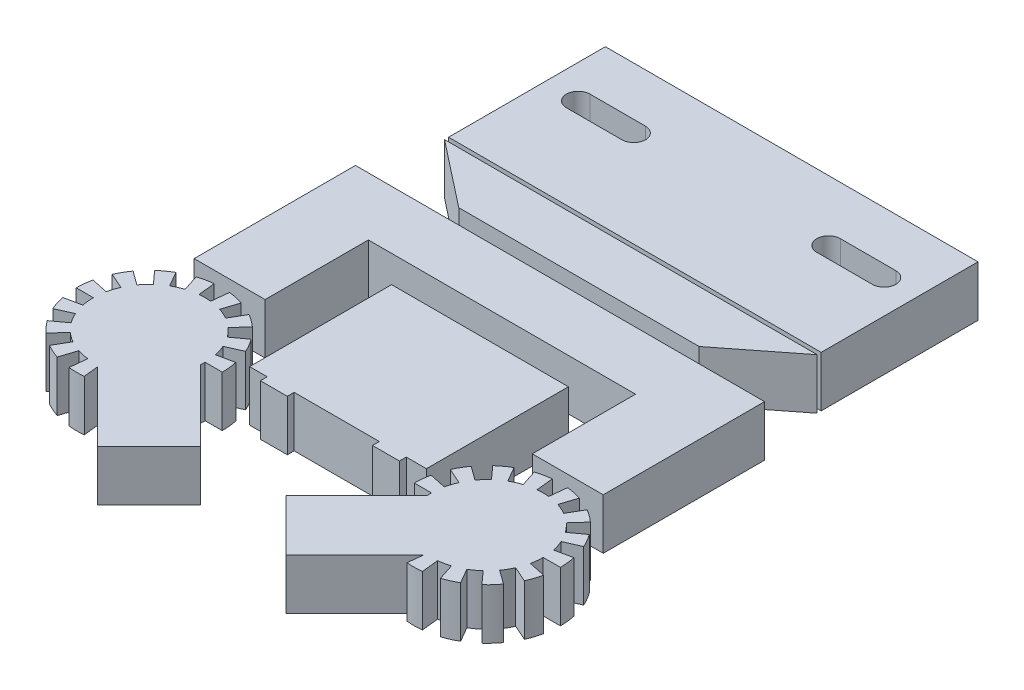
from build123d import *

# Parameters (mm, degrees)
SKETCH1_W           = 34.872727273
SKETCH1_H           = 28
SKETCH1_W_2         = 73.493872484
SKETCH1_H_2         = 30.925305247
SKETCH1_W_3         = 5.310911144
SKETCH1_H_3         = 1.348863037
BOSS_EXTRUDE1_DEPTH = 10


with BuildPart() as part:
    # Sketch1 → Boss-Extrude1 (new body)
    with BuildSketch(Plane(origin=(0, 0, 0), x_dir=(1, 0, 0), z_dir=(0, 1, 0))):
        with BuildLine():
            Line((-23.273628157, -7.68497585), (-20.186345058, -6.310428855))
            ThreePointArc((-20.186345058, -6.310428855), (-20.870633833, -4.967436515), (-21.691554929, -3.703328882))
            Line((-21.691554929, -3.703328882), (-24.425589095, -5.689720977))
            ThreePointArc((-24.425589095, -5.689720977), (-25.151536489, -4.793250604), (-25.967213737, -3.977573356))
            Line((-25.967213737, -3.977573356), (-23.705918916, -1.466151028))
            ThreePointArc((-23.705918916, -1.466151028), (-24.877292015, -0.517591796), (-26.141399648, 0.303329299))
            Line((-26.141399648, 0.303329299), (-27.831125689, -2.623362055))
            ThreePointArc((-27.831125689, -2.623362055), (-28.858938983, -2.099665024), (-29.935863054, -1.686272605))
            Line((-29.935863054, -1.686272605), (-28.891554929, 1.52777732))
            ThreePointArc((-28.891554929, 1.52777732), (-30.3474713, 1.917888936), (-31.836189777, 2.153678778))
            Line((-31.836189777, 2.153678778), (-32.18943871, -1.207260312))
            ThreePointArc((-32.18943871, -1.207260312), (-33.341399648, -1.146888597), (-34.493360586, -1.207260312))
            Line((-34.493360586, -1.207260312), (-34.846609519, 2.153678778))
            ThreePointArc((-34.846609519, 2.153678778), (-36.335327996, 1.917888936), (-37.791244367, 1.52777732))
            Line((-37.791244367, 1.52777732), (-36.746936242, -1.686272605))
            ThreePointArc((-36.746936242, -1.686272605), (-37.823860313, -2.099665024), (-38.851673607, -2.623362055))
            Line((-38.851673607, -2.623362055), (-40.541399648, 0.303329299))
            ThreePointArc((-40.541399648, 0.303329299), (-41.805507281, -0.517591796), (-42.976880379, -1.466151028))
            Line((-42.976880379, -1.466151028), (-40.715585558, -3.977573356))
            ThreePointArc((-40.715585558, -3.977573356), (-41.531262807, -4.793250604), (-42.257210201, -5.689720977))
            Line((-42.257210201, -5.689720977), (-44.991244367, -3.703328882))
            ThreePointArc((-44.991244367, -3.703328882), (-45.812165462, -4.967436515), (-46.496454238, -6.310428855))
            Line((-46.496454238, -6.310428855), (-43.409171139, -7.68497585))
            ThreePointArc((-43.409171139, -7.68497585), (-43.822563558, -8.761899921), (-44.121122152, -9.876135764))
            Line((-44.121122152, -9.876135764), (-47.426725098, -9.173508167))
            ThreePointArc((-47.426725098, -9.173508167), (-47.662514941, -10.662226644), (-47.741399648, -12.167436515))
            Line((-47.741399648, -12.167436515), (-44.361947566, -12.167436515))
            ThreePointArc((-44.361947566, -12.167436515), (-44.301575851, -13.319397453), (-44.121122152, -14.458737266))
            Line((-44.121122152, -14.458737266), (-47.426725098, -15.161364863))
            ThreePointArc((-47.426725098, -15.161364863), (-47.036613482, -16.617281234), (-46.496454238, -18.024444175))
            Line((-46.496454238, -18.024444175), (-43.409171139, -16.64989718))
            ThreePointArc((-43.409171139, -16.64989718), (-42.885474108, -17.677710474), (-42.257210201, -18.645152053))
            Line((-42.257210201, -18.645152053), (-44.991244367, -20.631544148))
            ThreePointArc((-44.991244367, -20.631544148), (-44.042685135, -21.802917247), (-42.976880379, -22.868722002))
            Line((-42.976880379, -22.868722002), (-40.715585558, -20.357299674))
            ThreePointArc((-40.715585558, -20.357299674), (-39.819115186, -21.083247068), (-38.851673607, -21.711510975))
            Line((-38.851673607, -21.711510975), (-40.541399648, -24.63820233))
            ThreePointArc((-40.541399648, -24.63820233), (-39.198407308, -25.322491105), (-37.791244367, -25.86265035))
            Line((-37.791244367, -25.86265035), (-36.746936242, -22.648600425))
            ThreePointArc((-36.746936242, -22.648600425), (-35.632700399, -22.94715902), (-34.493360586, -23.127612718))
            Line((-34.493360586, -23.127612718), (-34.846609519, -26.488551808))
            ThreePointArc((-34.846609519, -26.488551808), (-33.341399648, -26.567436515), (-31.836189777, -26.488551808))
            Line((-31.836189777, -26.488551808), (-32.139123373, -23.606331173))
            Line((-32.139123373, -23.606331173), (-18.581818182, -37.163636364))
            Line((-18.581818182, -37.163636364), (-8.4, -26.981818182))
            Line((-8.4, -26.981818182), (-22.354452896, -13.027365285))
            ThreePointArc((-22.354452896, -13.027365285), (-22.329255226, -12.597729011), (-22.32085173, -12.167436515))
            Line((-22.32085173, -12.167436515), (-18.941399648, -12.167436515))
            ThreePointArc((-18.941399648, -12.167436515), (-19.020284355, -10.662226644), (-19.256074197, -9.173508167))
            Line((-19.256074197, -9.173508167), (-22.561677143, -9.876135764))
            ThreePointArc((-22.561677143, -9.876135764), (-22.860235737, -8.761899921), (-23.273628157, -7.68497585))
        make_face()
        with BuildLine():
            ThreePointArc((18.941399648, -12.167436515), (19.020284355, -10.662226644), (19.256074197, -9.173508167))
            Line((19.256074197, -9.173508167), (22.561677143, -9.876135764))
            ThreePointArc((22.561677143, -9.876135764), (22.860235737, -8.761899921), (23.273628157, -7.68497585))
            Line((23.273628157, -7.68497585), (20.186345058, -6.310428855))
            ThreePointArc((20.186345058, -6.310428855), (20.870633833, -4.967436515), (21.691554929, -3.703328882))
            Line((21.691554929, -3.703328882), (24.425589095, -5.689720977))
            ThreePointArc((24.425589095, -5.689720977), (25.151536489, -4.793250604), (25.967213737, -3.977573356))
            Line((25.967213737, -3.977573356), (23.705918916, -1.466151028))
            ThreePointArc((23.705918916, -1.466151028), (24.877292015, -0.517591796), (26.141399648, 0.303329299))
            Line((26.141399648, 0.303329299), (27.831125689, -2.623362055))
            ThreePointArc((27.831125689, -2.623362055), (28.858938983, -2.099665024), (29.935863054, -1.686272605))
            Line((29.935863054, -1.686272605), (28.891554929, 1.52777732))
            ThreePointArc((28.891554929, 1.52777732), (30.3474713, 1.917888936), (31.836189777, 2.153678778))
            Line((31.836189777, 2.153678778), (32.18943871, -1.207260312))
            ThreePointArc((32.18943871, -1.207260312), (33.341399648, -1.146888597), (34.493360586, -1.207260312))
            Line((34.493360586, -1.207260312), (34.846609519, 2.153678778))
            ThreePointArc((34.846609519, 2.153678778), (36.335327996, 1.917888936), (37.791244367, 1.52777732))
            Line((37.791244367, 1.52777732), (36.746936242, -1.686272605))
            ThreePointArc((36.746936242, -1.686272605), (37.823860313, -2.099665024), (38.851673607, -2.623362055))
            Line((38.851673607, -2.623362055), (40.541399648, 0.303329299))
            ThreePointArc((40.541399648, 0.303329299), (41.805507281, -0.517591796), (42.976880379, -1.466151028))
            Line((42.976880379, -1.466151028), (40.715585558, -3.977573356))
            ThreePointArc((40.715585558, -3.977573356), (41.531262807, -4.793250604), (42.257210201, -5.689720977))
            Line((42.257210201, -5.689720977), (44.991244367, -3.703328882))
            ThreePointArc((44.991244367, -3.703328882), (45.812165462, -4.967436515), (46.496454238, -6.310428855))
            Line((46.496454238, -6.310428855), (43.409171139, -7.68497585))
            ThreePointArc((43.409171139, -7.68497585), (43.822563558, -8.761899921), (44.121122152, -9.876135764))
            Line((44.121122152, -9.876135764), (47.426725098, -9.173508167))
            ThreePointArc((47.426725098, -9.173508167), (47.662514941, -10.662226644), (47.741399648, -12.167436515))
            Line((47.741399648, -12.167436515), (44.361947566, -12.167436515))
            ThreePointArc((44.361947566, -12.167436515), (44.301575851, -13.319397453), (44.121122152, -14.458737266))
            Line((44.121122152, -14.458737266), (47.426725098, -15.161364863))
            ThreePointArc((47.426725098, -15.161364863), (47.036613482, -16.617281234), (46.496454238, -18.024444175))
            Line((46.496454238, -18.024444175), (43.409171139, -16.64989718))
            ThreePointArc((43.409171139, -16.64989718), (42.885474108, -17.677710474), (42.257210201, -18.645152053))
            Line((42.257210201, -18.645152053), (44.991244367, -20.631544148))
            ThreePointArc((44.991244367, -20.631544148), (44.042685135, -21.802917247), (42.976880379, -22.868722002))
            Line((42.976880379, -22.868722002), (40.715585558, -20.357299674))
            ThreePointArc((40.715585558, -20.357299674), (39.819115186, -21.083247068), (38.851673607, -21.711510975))
            Line((38.851673607, -21.711510975), (40.541399648, -24.63820233))
            ThreePointArc((40.541399648, -24.63820233), (39.198407308, -25.322491105), (37.791244367, -25.86265035))
            Line((37.791244367, -25.86265035), (36.746936242, -22.648600425))
            ThreePointArc((36.746936242, -22.648600425), (35.632700399, -22.94715902), (34.493360586, -23.127612718))
            Line((34.493360586, -23.127612718), (34.846609519, -26.488551808))
            ThreePointArc((34.846609519, -26.488551808), (33.341399648, -26.567436515), (31.836189777, -26.488551808))
            Line((31.836189777, -26.488551808), (32.139123373, -23.606331173))
            Line((32.139123373, -23.606331173), (18.581818182, -37.163636364))
            Line((18.581818182, -37.163636364), (8.4, -26.981818182))
            Line((8.4, -26.981818182), (22.354452896, -13.027365285))
            ThreePointArc((22.354452896, -13.027365285), (22.329255226, -12.597729011), (22.32085173, -12.167436515))
            Line((22.32085173, -12.167436515), (18.941399648, -12.167436515))
        make_face()
        with Locations((0.254545455, 5.472727273)):
            Rectangle(SKETCH1_W, SKETCH1_H)
        Polygon((-27.109090909, 4.454545455), (-41.109090909, 4.454545455), (-41.109090909, 36.272727273), (39.581818182, 36.272727273), (39.581818182, 4.454545455), (25.581818182, 4.454545455), (25.581818182, 24.818181818), (-27.109090909, 24.818181818), align=None)
        Polygon((23.705918916, 39.242717593), (-23.705918916, 39.242717593), (-36.746936242, 49.476854674), (36.746936242, 49.476854674), align=None)
        with Locations((0, 65.739350238)):
            Rectangle(SKETCH1_W_2, SKETCH1_H_2)
        with BuildLine():
            ThreePointArc((-19.21660374, 66.929718355), (-16.887413584, 69.258908511), (-19.21660374, 71.588098667))
            Line((-19.21660374, 71.588098667), (-30.162795949, 71.588098667))
            ThreePointArc((-30.162795949, 71.588098667), (-32.491986105, 69.258908511), (-30.162795949, 66.929718355))
            Line((-30.162795949, 66.929718355), (-19.21660374, 66.929718355))
        make_face(mode=Mode.SUBTRACT)
        with BuildLine():
            Line((30.162795949, 66.929718355), (19.21660374, 66.929718355))
            ThreePointArc((19.21660374, 66.929718355), (16.887413584, 69.258908511), (19.21660374, 71.588098667))
            Line((19.21660374, 71.588098667), (30.162795949, 71.588098667))
            ThreePointArc((30.162795949, 71.588098667), (32.491986105, 69.258908511), (30.162795949, 66.929718355))
        make_face(mode=Mode.SUBTRACT)
        with Locations((-11.055455572, -9.201704246)):
            Rectangle(SKETCH1_W_3, SKETCH1_H_3)
        with Locations((11.055455572, -9.201704246)):
            Rectangle(SKETCH1_W_3, SKETCH1_H_3)
    extrude(amount=BOSS_EXTRUDE1_DEPTH)


solid = part.part
